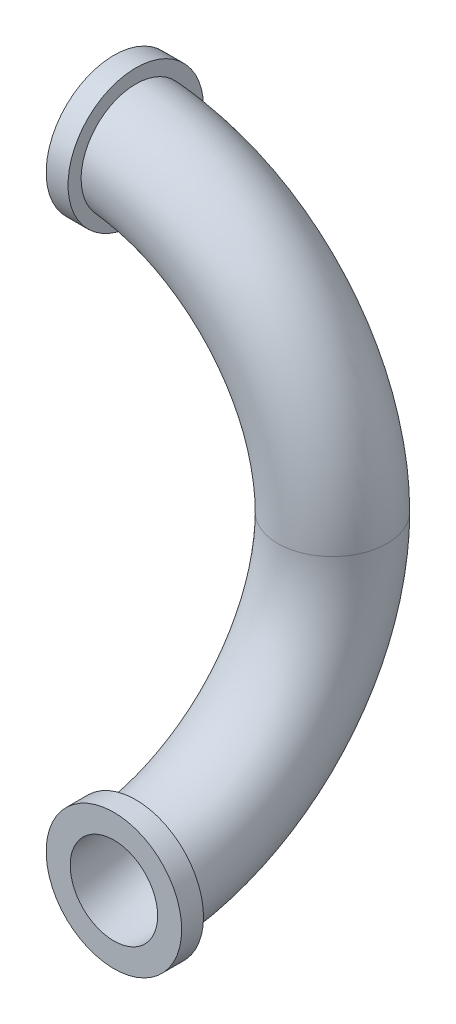
from build123d import *

# Parameters (mm, degrees)
IZIM4_R   = 0.25
IZIM4_R_2 = 0.2
IZIM5_R   = 0.31
IZIM5_R_2 = 0.21
IZIM6_R   = 0.31
IZIM6_R_2 = 0.21


with BuildPart() as part:
    # Süpür-İnce1: sweep along a curve in space
    with BuildLine() as s_p_r_nce1_path:
        ThreePointArc((0, 0, 0), (-0.292893219, 0.707106781, 0), (-1, 1, 0))
        ThreePointArc((0, 0, 0), (0, -0.707106781, 0.292893219), (0, -1, 1))
    # Çizim4 → Süpür-İnce1 (sweep)
    with BuildSketch(Plane.XY.offset(1)):
        with Locations((0, -1)):
            Circle(IZIM4_R)
        with Locations((0, -1)):
            Circle(IZIM4_R_2, mode=Mode.SUBTRACT)
    sweep(path=s_p_r_nce1_path.line)

    # Süpür-İnce2: sweep along a path in Çizim2
    with BuildLine(Plane(origin=(0, 0, 0), x_dir=(0, 0, -1), z_dir=(1, 0, 0))) as s_p_r_nce2_path:
        Line((-1, -1), (-0.9, -1))
    # Çizim5 → Süpür-İnce2 (sweep)
    with BuildSketch(Plane.XY.offset(1)):
        with Locations((0, -1)):
            Circle(IZIM5_R)
        with Locations((0, -1)):
            Circle(IZIM5_R_2, mode=Mode.SUBTRACT)
    sweep(path=s_p_r_nce2_path.line)

    # Süpür-İnce3: sweep along a path in Çizim3
    with BuildLine(Plane.XY) as s_p_r_nce3_path:
        Line((-1, 1), (-0.9, 1))
    # Çizim6 → Süpür-İnce3 (sweep)
    with BuildSketch(Plane(origin=(-1, 0, 0), x_dir=(0, 0, -1), z_dir=(1, 0, 0))):
        with Locations((0, 1)):
            Circle(IZIM6_R)
        with Locations((0, 1)):
            Circle(IZIM6_R_2, mode=Mode.SUBTRACT)
    sweep(path=s_p_r_nce3_path.line)


solid = part.part
